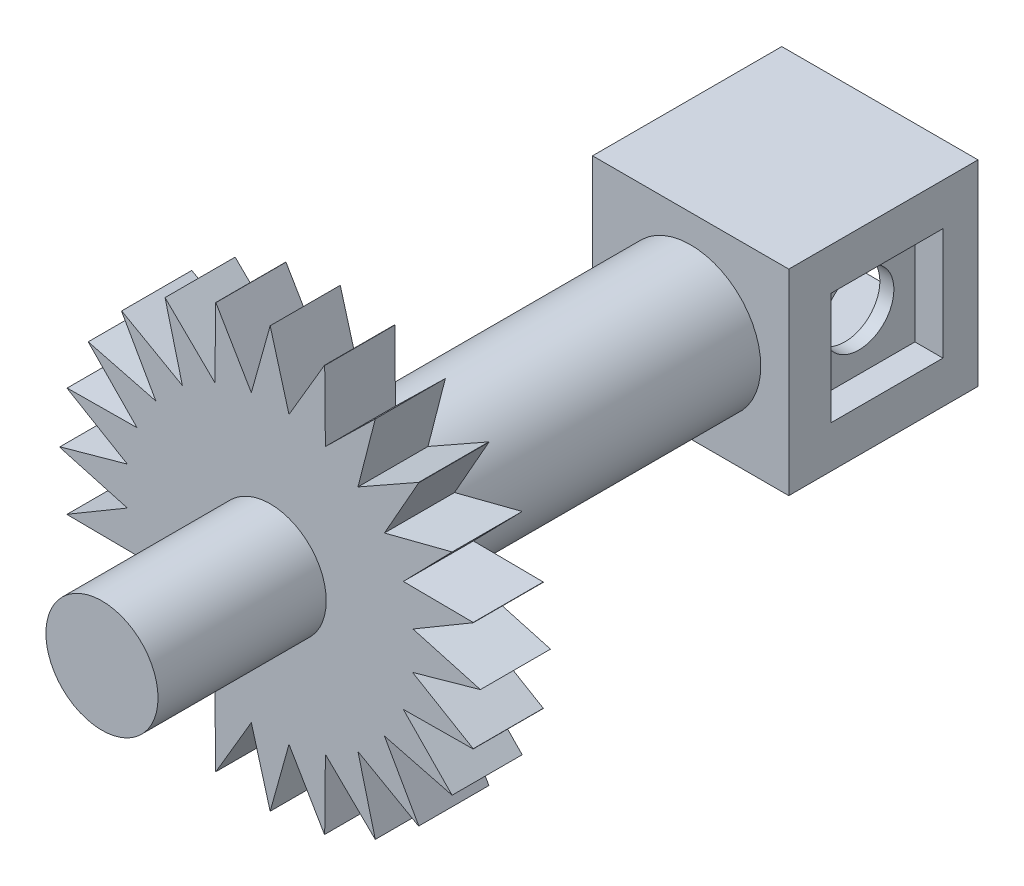
from build123d import *

# Parameters (mm, degrees)
ESQUISSE1_R             = 5
BOSS_EXTRU_2_DEPTH      = 70
ESQUISSE2_R             = 3.5
BOSS_EXTRU_3_DEPTH      = 12
ESQUISSE4_R             = 15
BOSS_EXTRU_5_DEPTH      = 5
ESQUISSE5_R             = 3.5
BOSS_EXTRU_6_DEPTH      = 12
ENL_V_MAT_EXTRU_1_DEPTH = 12
ESQUISSE7_R             = 5
ENL_V_MAT_EXTRU_2_DEPTH = 47
ESQUISSE8_W             = 14
ESQUISSE8_H             = 14
BOSS_EXTRU_7_DEPTH      = 5
ESQUISSE9_W             = 14
ESQUISSE9_H             = 14
ESQUISSE9_W_2           = 8
ESQUISSE9_H_2           = 8
BOSS_EXTRU_8_DEPTH      = 4.5
ESQUISSE10_W            = 8
ESQUISSE10_H            = 8
ENL_V_MAT_EXTRU_3_DEPTH = 3.5
ESQUISSE12_W            = 14
ESQUISSE12_H            = 14
ESQUISSE12_W_2          = 8
ESQUISSE12_H_2          = 8
BOSS_EXTRU_9_DEPTH      = 4
ESQUISSE14_W            = 8
ESQUISSE14_H            = 8
ENL_V_MAT_EXTRU_4_DEPTH = 2
ESQUISSE15_R            = 2.5
ENL_V_MAT_EXTRU_5_DEPTH = 2
ESQUISSE16_W            = 8
ESQUISSE16_H            = 8
ENL_V_MAT_EXTRU_6_DEPTH = 2
ESQUISSE17_R            = 2.5
ENL_V_MAT_EXTRU_7_DEPTH = 2
ESQUISSE18_R            = 4
BOSS_EXTRU_10_DEPTH     = 12


with BuildPart() as part:
    # Esquisse1 → Boss.-Extru.2 (new body)
    with BuildSketch(Plane.XY):
        Circle(ESQUISSE1_R)
    extrude(amount=BOSS_EXTRU_2_DEPTH)

    # Esquisse2 → Boss.-Extru.3 (add)
    with BuildSketch(Plane(origin=(0, 0, 0), x_dir=(-1, 0, 0), z_dir=(0, 0, -1))):
        Circle(ESQUISSE2_R)
    extrude(amount=BOSS_EXTRU_3_DEPTH)

    # Esquisse4 → Boss.-Extru.5 (add)
    with BuildSketch(Plane.XY.offset(70)):
        Circle(ESQUISSE4_R)
    extrude(amount=-BOSS_EXTRU_5_DEPTH)

    # Esquisse5 → Boss.-Extru.6 (add)
    with BuildSketch(Plane.XY.offset(70)):
        Circle(ESQUISSE5_R)
    extrude(amount=BOSS_EXTRU_6_DEPTH)

    # Esquisse6 → Enlèv. mat.-Extru.1 (cut)
    with BuildSketch(Plane.XY.offset(70)):
        with BuildLine():
            Line((-6.262893089, 8.172072336), (-7.499435292, 12.990707074))
            ThreePointArc((-7.499435292, 12.990707074), (-9.123657799, 11.90625333), (-10.593218546, 10.619968024))
            Line((-10.593218546, 10.619968024), (-6.262893089, 8.172072336))
        make_face()
        with BuildLine():
            Line((-8.152402023, 6.270263162), (-10.606442664, 10.606760769))
            ThreePointArc((-10.606442664, 10.606760769), (-11.894621233, 9.138817524), (-12.981158937, 7.515950549))
            Line((-12.981158937, 7.515950549), (-8.152402023, 6.270263162))
        make_face()
        with BuildLine():
            Line((-9.499942261, 3.951679007), (-12.981158937, 7.515950549))
            ThreePointArc((-12.981158937, 7.515950549), (-13.849269023, 5.761748652), (-14.481582106, 3.909447494))
            Line((-14.481582106, 3.909447494), (-9.499942261, 3.951679007))
        make_face()
        with BuildLine():
            Line((-10.188028074, 1.356459322), (-14.486441985, 3.891400598))
            ThreePointArc((-14.486441985, 3.891400598), (-14.869805294, 1.972027008), (-14.999987869, 0.0190767))
            Line((-14.999987869, 0.0190767), (-10.188028074, 1.356459322))
        make_face()
        with BuildLine():
            ThreePointArc((-14.999987869, -0.0190767), (-14.869805294, -1.972027008), (-14.486441985, -3.891400598))
            Line((-14.486441985, -3.891400598), (-10.188028074, -1.356459322))
            Line((-10.188028074, -1.356459322), (-14.999987869, -0.0190767))
        make_face()
        with BuildLine():
            Line((-9.499942261, -3.951679007), (-14.481582106, -3.909447494))
            ThreePointArc((-14.481582106, -3.909447494), (-13.849269023, -5.761748652), (-12.981158937, -7.515950549))
            Line((-12.981158937, -7.515950549), (-9.499942261, -3.951679007))
        make_face()
        with BuildLine():
            Line((-8.152402023, -6.270263162), (-12.981158937, -7.515950549))
            ThreePointArc((-12.981158937, -7.515950549), (-11.894621233, -9.138817524), (-10.606442664, -10.606760769))
            Line((-10.606442664, -10.606760769), (-8.152402023, -6.270263162))
        make_face()
        with BuildLine():
            Line((-6.262893089, -8.172072336), (-10.593218546, -10.619968024))
            ThreePointArc((-10.593218546, -10.619968024), (-9.123657799, -11.90625333), (-7.499435292, -12.990707074))
            Line((-7.499435292, -12.990707074), (-6.262893089, -8.172072336))
        make_face()
        with BuildLine():
            Line((-3.939593974, -9.504960245), (-7.499435292, -12.990707074))
            ThreePointArc((-7.499435292, -12.990707074), (-5.744130769, -13.8565855), (-3.891026946, -14.486542352))
            Line((-3.891026946, -14.486542352), (-3.939593974, -9.504960245))
        make_face()
        with BuildLine():
            Line((-1.343501295, -10.189744953), (-3.872973884, -14.491379275))
            ThreePointArc((-3.872973884, -14.491379275), (-1.953114292, -14.872301253), (0, -15))
            Line((0, -15), (-1.343501295, -10.189744953))
        make_face()
        with BuildLine():
            ThreePointArc((0, -15), (1.953114292, -14.872301253), (3.872973884, -14.491379275))
            Line((3.872973884, -14.491379275), (1.343501295, -10.189744953))
            Line((1.343501295, -10.189744953), (0, -15))
        make_face()
        with BuildLine():
            ThreePointArc((3.891026946, -14.486542352), (5.744130769, -13.8565855), (7.499435292, -12.990707074))
            Line((7.499435292, -12.990707074), (3.939593974, -9.504960245))
            Line((3.939593974, -9.504960245), (3.891026946, -14.486542352))
        make_face()
        with BuildLine():
            ThreePointArc((7.499435292, -12.990707074), (9.123657799, -11.90625333), (10.593218546, -10.619968024))
            Line((10.593218546, -10.619968024), (6.262893089, -8.172072336))
            Line((6.262893089, -8.172072336), (7.499435292, -12.990707074))
        make_face()
        with BuildLine():
            ThreePointArc((10.606442664, -10.606760769), (11.894621233, -9.138817524), (12.981158937, -7.515950549))
            Line((12.981158937, -7.515950549), (8.152402023, -6.270263162))
            Line((8.152402023, -6.270263162), (10.606442664, -10.606760769))
        make_face()
        with BuildLine():
            ThreePointArc((12.981158937, -7.515950549), (13.849269023, -5.761748652), (14.481582106, -3.909447494))
            Line((14.481582106, -3.909447494), (9.499942261, -3.951679007))
            Line((9.499942261, -3.951679007), (12.981158937, -7.515950549))
        make_face()
        with BuildLine():
            ThreePointArc((15, 0), (14.999996967, 0.009538352), (14.999987869, 0.0190767))
            Line((14.999987869, 0.0190767), (10.159352957, -1.339548494))
            Line((10.159352957, -1.339548494), (14.486441985, -3.891400598))
            ThreePointArc((14.486441985, -3.891400598), (14.87105628, -1.962571047), (15, 0))
        make_face()
        with BuildLine():
            ThreePointArc((14.999987869, 0.0190767), (14.869805294, 1.972027008), (14.486441985, 3.891400598))
            Line((14.486441985, 3.891400598), (10.188028074, 1.356459322))
            Line((10.188028074, 1.356459322), (14.999987869, 0.0190767))
        make_face()
        with BuildLine():
            ThreePointArc((14.481582106, 3.909447494), (13.849269023, 5.761748652), (12.981158937, 7.515950549))
            Line((12.981158937, 7.515950549), (9.499942261, 3.951679007))
            Line((9.499942261, 3.951679007), (14.481582106, 3.909447494))
        make_face()
        with BuildLine():
            ThreePointArc((12.981158937, 7.515950549), (11.894621233, 9.138817524), (10.606442664, 10.606760769))
            Line((10.606442664, 10.606760769), (8.152402023, 6.270263162))
            Line((8.152402023, 6.270263162), (12.981158937, 7.515950549))
        make_face()
        with BuildLine():
            ThreePointArc((10.593218546, 10.619968024), (9.123657799, 11.90625333), (7.499435292, 12.990707074))
            Line((7.499435292, 12.990707074), (6.262893089, 8.172072336))
            Line((6.262893089, 8.172072336), (10.593218546, 10.619968024))
        make_face()
        with BuildLine():
            ThreePointArc((7.499435292, 12.990707074), (5.744130769, 13.8565855), (3.891026946, 14.486542352))
            Line((3.891026946, 14.486542352), (3.939593974, 9.504960245))
            Line((3.939593974, 9.504960245), (7.499435292, 12.990707074))
        make_face()
        with BuildLine():
            ThreePointArc((3.872973884, 14.491379275), (1.953114292, 14.872301253), (0, 15))
            Line((0, 15), (1.343501295, 10.189744953))
            Line((1.343501295, 10.189744953), (3.872973884, 14.491379275))
        make_face()
        with BuildLine():
            Line((-1.343501295, 10.189744953), (0, 15))
            ThreePointArc((0, 15), (-1.953114292, 14.872301253), (-3.872973884, 14.491379275))
            Line((-3.872973884, 14.491379275), (-1.343501295, 10.189744953))
        make_face()
        with BuildLine():
            Line((-3.939593974, 9.504960245), (-3.891026946, 14.486542352))
            ThreePointArc((-3.891026946, 14.486542352), (-5.744130769, 13.8565855), (-7.499435292, 12.990707074))
            Line((-7.499435292, 12.990707074), (-3.939593974, 9.504960245))
        make_face()
    extrude(amount=-ENL_V_MAT_EXTRU_1_DEPTH, mode=Mode.SUBTRACT)

    # Esquisse7 → Enlèv. mat.-Extru.2 (cut)
    with BuildSketch(Plane(origin=(0, 0, -12), x_dir=(-1, 0, 0), z_dir=(0, 0, -1))):
        Circle(ESQUISSE7_R)
    extrude(amount=-ENL_V_MAT_EXTRU_2_DEPTH, mode=Mode.SUBTRACT)

    # Esquisse8 → Boss.-Extru.7 (add)
    with BuildSketch(Plane(origin=(0, 0, 35), x_dir=(-1, 0, 0), z_dir=(0, 0, -1))):
        Rectangle(ESQUISSE8_W, ESQUISSE8_H)
    extrude(amount=-BOSS_EXTRU_7_DEPTH)

    # Esquisse9 → Boss.-Extru.8 (add)
    with BuildSketch(Plane(origin=(0, 0, 35), x_dir=(-1, 0, 0), z_dir=(0, 0, -1))):
        Rectangle(ESQUISSE9_W, ESQUISSE9_H)
        Rectangle(ESQUISSE9_W_2, ESQUISSE9_H_2, mode=Mode.SUBTRACT)
    extrude(amount=BOSS_EXTRU_8_DEPTH)

    # Esquisse10 → Enlèv. mat.-Extru.3 (cut)
    with BuildSketch(Plane(origin=(0, 0, 35), x_dir=(-1, 0, 0), z_dir=(0, 0, -1))):
        Rectangle(ESQUISSE10_W, ESQUISSE10_H)
    extrude(amount=-ENL_V_MAT_EXTRU_3_DEPTH, mode=Mode.SUBTRACT)

    # Esquisse12 → Boss.-Extru.9 (add)
    with BuildSketch(Plane(origin=(0, 0, 30.5), x_dir=(-1, 0, 0), z_dir=(0, 0, -1))):
        Rectangle(ESQUISSE12_W, ESQUISSE12_H)
        Rectangle(ESQUISSE12_W_2, ESQUISSE12_H_2, mode=Mode.SUBTRACT)
    extrude(amount=BOSS_EXTRU_9_DEPTH)

    # Esquisse14 → Enlèv. mat.-Extru.4 (cut)
    with BuildSketch(Plane.ZY.offset(7)):
        with Locations((33, 0)):
            Rectangle(ESQUISSE14_W, ESQUISSE14_H)
    extrude(amount=-ENL_V_MAT_EXTRU_4_DEPTH, mode=Mode.SUBTRACT)

    # Esquisse15 → Enlèv. mat.-Extru.5 (cut)
    with BuildSketch(Plane.ZY.offset(5)):
        with Locations((33, 0)):
            Circle(ESQUISSE15_R)
    extrude(amount=-ENL_V_MAT_EXTRU_5_DEPTH, mode=Mode.SUBTRACT)

    # Esquisse16 → Enlèv. mat.-Extru.6 (cut)
    with BuildSketch(Plane(origin=(7, 0, 0), x_dir=(0, 0, -1), z_dir=(1, 0, 0))):
        with Locations((-33, 0)):
            Rectangle(ESQUISSE16_W, ESQUISSE16_H)
    extrude(amount=-ENL_V_MAT_EXTRU_6_DEPTH, mode=Mode.SUBTRACT)

    # Esquisse17 → Enlèv. mat.-Extru.7 (cut)
    with BuildSketch(Plane(origin=(5, 0, 0), x_dir=(0, 0, -1), z_dir=(1, 0, 0))):
        with Locations((-33, 0)):
            Circle(ESQUISSE17_R)
    extrude(amount=-ENL_V_MAT_EXTRU_7_DEPTH, mode=Mode.SUBTRACT)

    # Esquisse18 → Boss.-Extru.10 (add)
    with BuildSketch(Plane.XY.offset(82)):
        Circle(ESQUISSE18_R)
    extrude(amount=-BOSS_EXTRU_10_DEPTH)


solid = part.part
